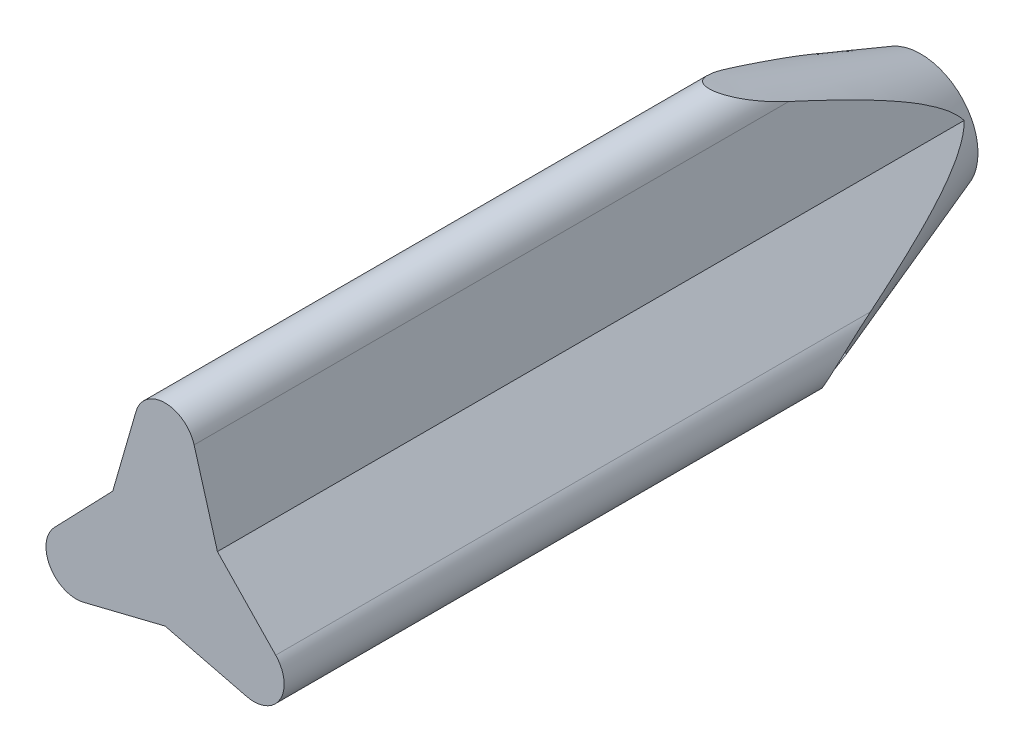
from build123d import *

# Parameters (mm, degrees)
BOSS_EXTRUDE1_DEPTH = 50
FILLET1_R           = 2


with BuildPart() as part:
    # Sketch1 → Boss-Extrude1 (new body)
    with BuildSketch(Plane.XY):
        Polygon((-12.124355653, -7), (-3.464101615, 2), (0, 14), (3.464101615, 2), (12.124355653, -7), (0, -4), align=None)
    extrude(amount=BOSS_EXTRUDE1_DEPTH)

    # Fillet1
    fillet1_edges = [part.edges().sort_by_distance(p)[0] for p in [
        (-12.124355653, -7, 25),
        (0, 14, 25),
        (12.124355653, -7, 25),
    ]]
    fillet(fillet1_edges, radius=FILLET1_R)

    # Sketch2 → Cut-Revolve1 (revolve, cut)
    with BuildSketch(Plane(origin=(0, 0, 0), x_dir=(0, 0, -1), z_dir=(1, 0, 0))):
        Polygon((0, 8.788897449), (0, 3.788897449), (-14, 8.788897449), align=None)
    revolve(axis=Axis((0, 0, 0), (0, 0, -1)), mode=Mode.SUBTRACT)


solid = part.part
